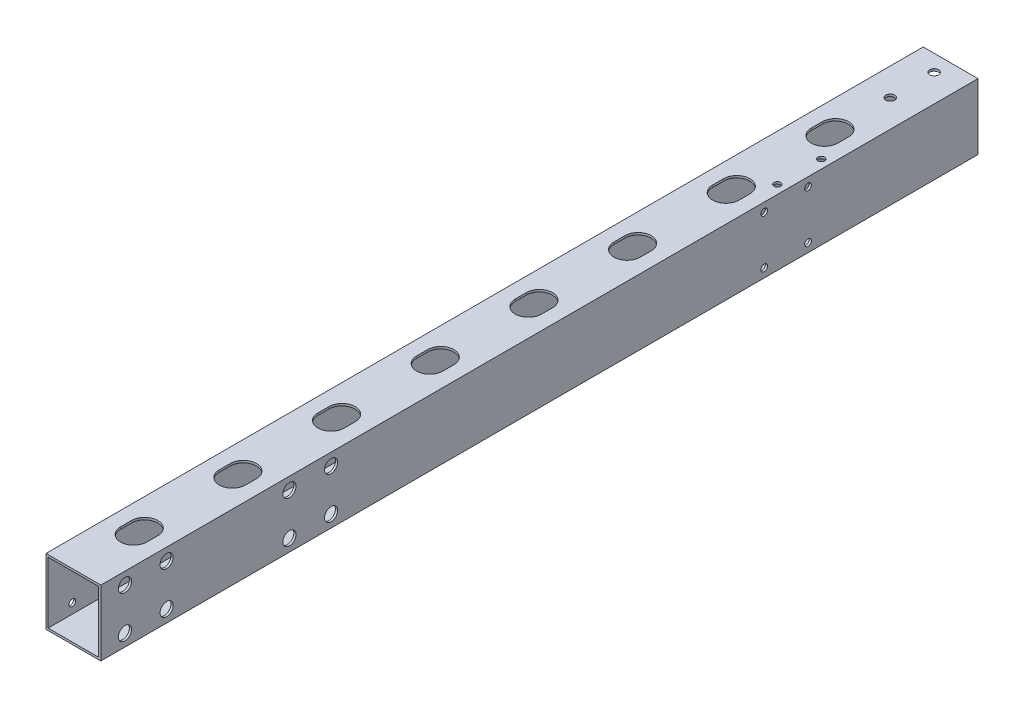
from build123d import *

# Parameters (mm, degrees)
SKETCH_1_W               = 25
SKETCH_1_H               = 30
EXTRUDE_1_DEPTH          = 200
SKETCH_2_OUTSIDE_W       = 107.38
SKETCH_2_OUTSIDE_H       = 112.38
SKETCH_2_OUTSIDE_W_2     = 25
SKETCH_2_OUTSIDE_H_2     = 30
SKETCH_2_OUTSIDE_W_3     = 23
SKETCH_2_OUTSIDE_H_3     = 28
CUT_EXTRUDE_1_DEPTH      = 200
SKETCH_3_R               = 2.025
CUT_EXTRUDE_2_DEPTH      = 31
SKETCH_4_R               = 1.525
CUT_EXTRUDE_3_DEPTH      = 1
CUT_EXTRUDE_3_DEPTH_BACK = 26
SKETCH_5_R               = 1.525
CUT_EXTRUDE_4_DEPTH      = 1
CUT_EXTRUDE_4_DEPTH_BACK = 26
SKETCH_6_R               = 3
CUT_EXTRUDE_5_DEPTH      = 5
SKETCH_7_R               = 3
CUT_EXTRUDE_6_DEPTH      = 5
CUT_EXTRUDE_START        = -31
CUT_EXTRUDE_7_DEPTH      = 32
PATTERN_LINEAR_1_COUNT   = 8
PATTERN_LINEAR_1_PITCH   = 45
SKETCH_10_R              = 1.525
CUT_EXTRUDE_9_DEPTH      = 31
SKETCH_11_R              = 1.525
CUT_EXTRUDE_10_DEPTH     = 3


with BuildPart() as part:
    # 草图1 → 凸台-拉伸1 (new body, symmetric)
    with BuildSketch(Plane.XY):
        Rectangle(SKETCH_1_W, SKETCH_1_H)
    extrude(amount=EXTRUDE_1_DEPTH, both=True)

    # 草图2 outside → 切除-拉伸1 (cut, symmetric)
    with BuildSketch(Plane.XY):
        Rectangle(SKETCH_2_OUTSIDE_W, SKETCH_2_OUTSIDE_H)
        Rectangle(SKETCH_2_OUTSIDE_W_2, SKETCH_2_OUTSIDE_H_2, mode=Mode.SUBTRACT)
        Rectangle(SKETCH_2_OUTSIDE_W_3, SKETCH_2_OUTSIDE_H_3)
    extrude(amount=CUT_EXTRUDE_1_DEPTH, both=True, mode=Mode.SUBTRACT)

    # 草图3 → 切除-拉伸2 (cut, through all)
    with BuildSketch(Plane(origin=(0, 15, 0), x_dir=(1, 0, 0), z_dir=(0, 1, 0))):
        with Locations((0, 172.5)):
            Circle(SKETCH_3_R)
        with Locations((0, 192.5)):
            Circle(SKETCH_3_R)
    extrude(amount=-CUT_EXTRUDE_2_DEPTH, mode=Mode.SUBTRACT)

    # 草图4 → 切除-拉伸3 (cut, two sides)
    with BuildSketch(Plane(origin=(12.5, 0, 0), x_dir=(0, 0, -1), z_dir=(1, 0, 0))) as cut_extrude_3_sk:
        with Locations((-170, -9.5)):
            Circle(SKETCH_4_R)
        with Locations((-189, -9.5)):
            Circle(SKETCH_4_R)
        with Locations((-189, 9.5)):
            Circle(SKETCH_4_R)
        with Locations((-170, 9.5)):
            Circle(SKETCH_4_R)
    extrude(amount=CUT_EXTRUDE_3_DEPTH, mode=Mode.SUBTRACT)
    extrude(cut_extrude_3_sk.sketch, amount=-CUT_EXTRUDE_3_DEPTH_BACK, mode=Mode.SUBTRACT)

    # 草图5 → 切除-拉伸4 (cut, two sides)
    with BuildSketch(Plane(origin=(12.5, 0, 0), x_dir=(0, 0, -1), z_dir=(1, 0, 0))) as cut_extrude_4_sk:
        with Locations((-95, 9.5)):
            Circle(SKETCH_5_R)
        with Locations((-114, 9.5)):
            Circle(SKETCH_5_R)
        with Locations((-114, -9.5)):
            Circle(SKETCH_5_R)
        with Locations((-95, -9.5)):
            Circle(SKETCH_5_R)
    extrude(amount=CUT_EXTRUDE_4_DEPTH, mode=Mode.SUBTRACT)
    extrude(cut_extrude_4_sk.sketch, amount=-CUT_EXTRUDE_4_DEPTH_BACK, mode=Mode.SUBTRACT)

    # 草图6 → 切除-拉伸5 (cut)
    with BuildSketch(Plane(origin=(12.5, 0, 0), x_dir=(0, 0, -1), z_dir=(1, 0, 0))):
        with Locations((-170, 9.5)):
            Circle(SKETCH_6_R)
        with Locations((-170, -9.5)):
            Circle(SKETCH_6_R)
        with Locations((-189, -9.5)):
            Circle(SKETCH_6_R)
        with Locations((-189, 9.5)):
            Circle(SKETCH_6_R)
    extrude(amount=-CUT_EXTRUDE_5_DEPTH, mode=Mode.SUBTRACT)

    # 草图7 → 切除-拉伸6 (cut)
    with BuildSketch(Plane(origin=(12.5, 0, 0), x_dir=(0, 0, -1), z_dir=(1, 0, 0))):
        with Locations((-114, 9.5)):
            Circle(SKETCH_7_R)
        with Locations((-95, 9.5)):
            Circle(SKETCH_7_R)
        with Locations((-95, -9.5)):
            Circle(SKETCH_7_R)
        with Locations((-114, -9.5)):
            Circle(SKETCH_7_R)
    extrude(amount=-CUT_EXTRUDE_6_DEPTH, mode=Mode.SUBTRACT)

    # 草图8 → 切除-拉伸7 (cut)
    with BuildSketch(Plane(origin=(0, 15, 0), x_dir=(1, 0, 0), z_dir=(0, 1, 0)).offset(CUT_EXTRUDE_START)):
        with BuildLine():
            Line((-6, -172.5), (-6, -167.5))
            ThreePointArc((-6, -167.5), (0, -161.5), (6, -167.5))
            Line((6, -167.5), (6, -172.5))
            ThreePointArc((6, -172.5), (0, -178.5), (-6, -172.5))
        make_face()
    cut_extrude_7 = extrude(amount=CUT_EXTRUDE_7_DEPTH, mode=Mode.SUBTRACT)

    # 阵列(线性)1: 切除-拉伸7 ×8
    with Locations(*[(0, 0, -i * PATTERN_LINEAR_1_PITCH) for i in range(1, PATTERN_LINEAR_1_COUNT)]):
        add(cut_extrude_7, mode=Mode.SUBTRACT)

    # 草图10 → 切除-拉伸9 (cut, through all)
    with BuildSketch(Plane(origin=(0, 15, 0), x_dir=(1, 0, 0), z_dir=(0, 1, 0))):
        with Locations((8.5, 112.5)):
            Circle(SKETCH_10_R)
        with Locations((8.5, 132.5)):
            Circle(SKETCH_10_R)
    extrude(amount=-CUT_EXTRUDE_9_DEPTH, mode=Mode.SUBTRACT)

    # 草图11 → 切除-拉伸10 (cut)
    with BuildSketch(Plane(origin=(12.5, 0, 0), x_dir=(0, 0, -1), z_dir=(1, 0, 0))):
        with Locations((122.5, 10.999999999)):
            Circle(SKETCH_11_R)
        with Locations((102.5, 10.999999999)):
            Circle(SKETCH_11_R)
        with Locations((102.5, -11)):
            Circle(SKETCH_11_R)
        with Locations((122.5, -11)):
            Circle(SKETCH_11_R)
    extrude(amount=-CUT_EXTRUDE_10_DEPTH, mode=Mode.SUBTRACT)


solid = part.part
